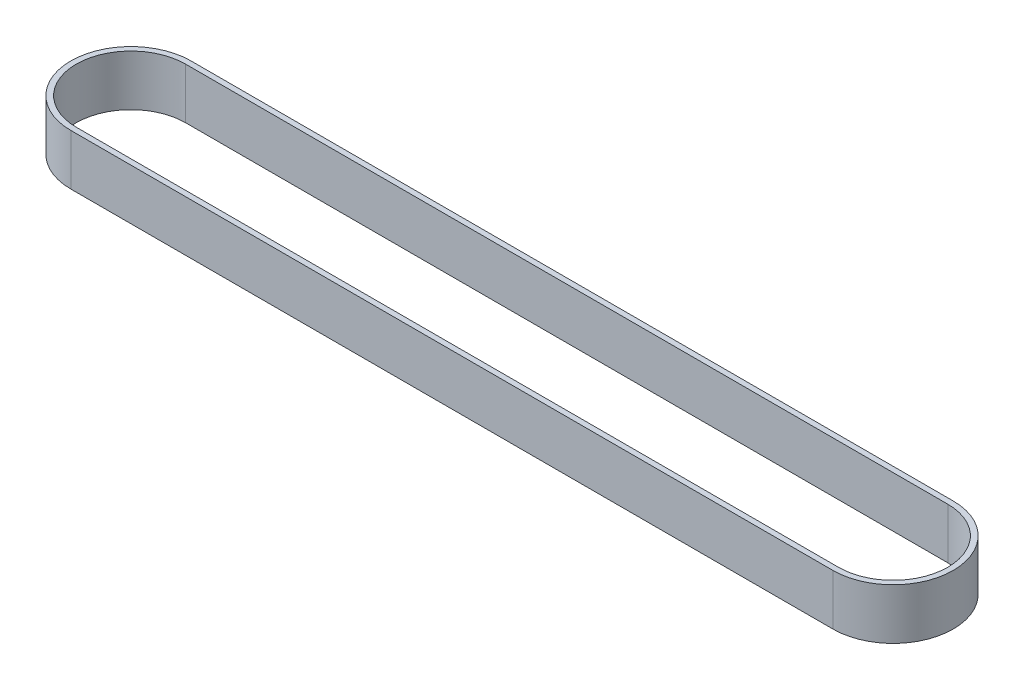
from build123d import *

# Parameters (mm, degrees)
BOSS_EXTRUDE2_DEPTH = 9.53
CUT_EXTRUDE1_DEPTH  = 10.53


with BuildPart() as part:
    # Sketch1 → Boss-Extrude2 (new body)
    with BuildSketch(Plane(origin=(0, 0, 0), x_dir=(1, 0, 0), z_dir=(0, 1, 0))):
        with BuildLine():
            Line((0, 11.285), (143, 11.285))
            ThreePointArc((143, 11.285), (154.285, 0), (143, -11.285))
            Line((143, -11.285), (0, -11.285))
            ThreePointArc((0, -11.285), (-11.285, 0), (0, 11.285))
        make_face()
    extrude(amount=BOSS_EXTRUDE2_DEPTH)

    # Sketch2 → Cut-Extrude1 (cut, through all)
    with BuildSketch(Plane(origin=(0, 9.53, 0), x_dir=(1, 0, 0), z_dir=(0, 1, 0))):
        with BuildLine():
            Line((0, 10.255), (143, 10.255))
            ThreePointArc((143, 10.255), (153.255, 0), (143, -10.255))
            Line((143, -10.255), (0, -10.255))
            ThreePointArc((0, -10.255), (-10.255, 0), (0, 10.255))
        make_face()
    extrude(amount=-CUT_EXTRUDE1_DEPTH, mode=Mode.SUBTRACT)


solid = part.part
